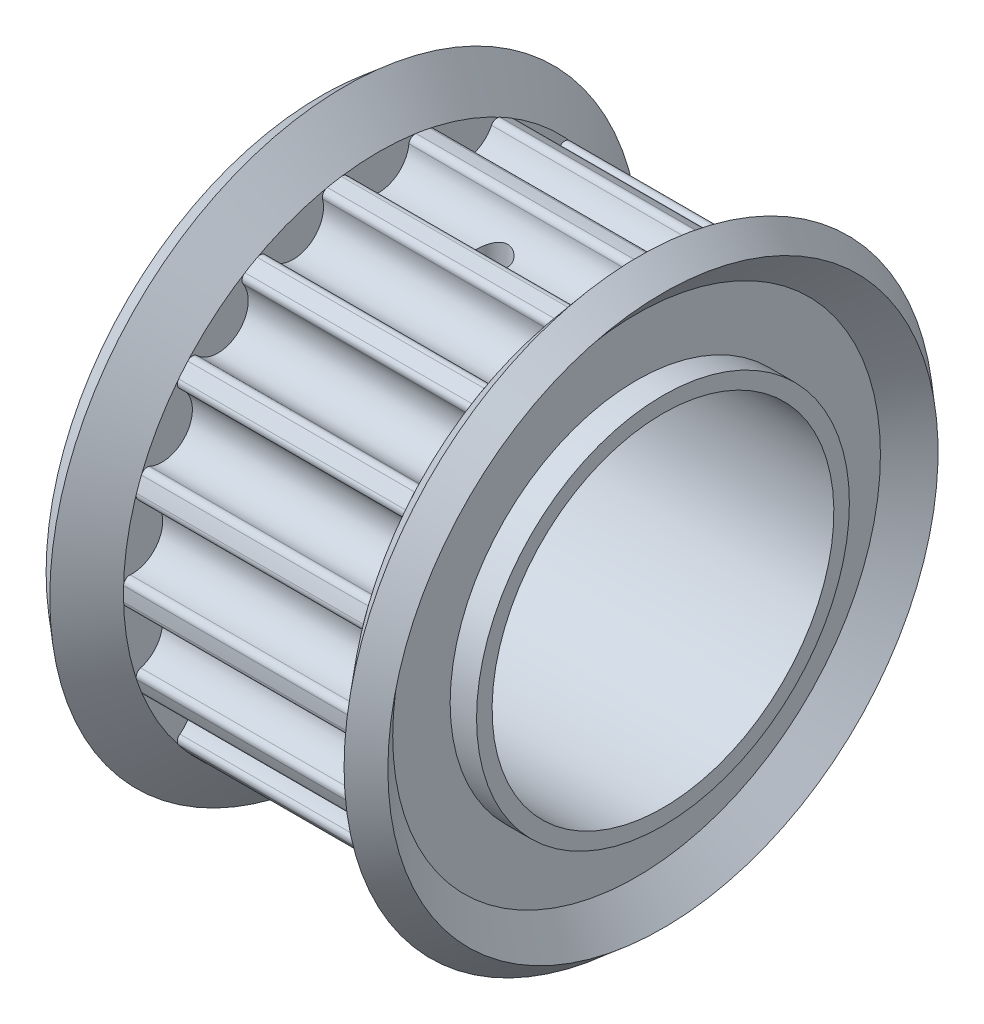
from build123d import *

# Parameters (mm, degrees)
CUT_EXTRUDE1_DEPTH = 6.5
CIRPATTERN1_COUNT  = 18
SKETCH4_W          = 11
SKETCH4_H          = 5.5
SKETCH5_R          = 0.5
CUT_EXTRUDE2_DEPTH = 10.5


with BuildPart() as part:
    # Sketch1 → Revolve1 (revolve)
    with BuildSketch(Plane.XY):
        Polygon((-5.5, 4), (5.5, 4), (5.5, 6), (3.65, 6), (3.65, 8.215), (-3.65, 8.215), (-3.65, 6), (-5.5, 6), align=None)
    revolve(axis=Axis((-16.041522885, 0, 0), (1, 0, 0)))

    # Sketch2 → Cut-Extrude1 (cut, symmetric)
    with BuildSketch(Plane(origin=(0, 0, 0), x_dir=(0, 0, -1), z_dir=(1, 0, 0))):
        with BuildLine():
            ThreePointArc((1.2, 8.126882859), (0, 8.215), (-1.2, 8.126882859))
            ThreePointArc((-1.2, 8.126882859), (-1.048214336, 8.087067355), (-0.971883761, 7.949962265))
            ThreePointArc((-0.971883761, 7.949962265), (0, 7.075), (0.971883761, 7.949962265))
            ThreePointArc((0.971883761, 7.949962265), (1.048214336, 8.087067355), (1.2, 8.126882859))
        make_face()
    cut_extrude1 = extrude(amount=CUT_EXTRUDE1_DEPTH, both=True, mode=Mode.SUBTRACT)

    # CirPattern1: Cut-Extrude1 ×18 about axis
    cirpattern1_axis = Axis((0, 0, 0), (1, 0, 0))
    for i in range(1, CIRPATTERN1_COUNT):
        add(cut_extrude1.rotate(cirpattern1_axis, i * 360 / CIRPATTERN1_COUNT), mode=Mode.SUBTRACT)

    # Sketch4 → Cut-Revolve1 (revolve, cut)
    with BuildSketch(Plane.XY):
        with Locations((0, 2.75)):
            Rectangle(SKETCH4_W, SKETCH4_H)
    revolve(axis=Axis((0, 0, 0), (-1, 0, 0)), mode=Mode.SUBTRACT)

    # Sketch5 → Cut-Extrude2 (cut, through all)
    with BuildSketch(Plane(origin=(0, 0, 0), x_dir=(1, 0, 0), z_dir=(0, 1, 0))):
        Circle(SKETCH5_R)
    extrude(amount=CUT_EXTRUDE2_DEPTH, mode=Mode.SUBTRACT)


with BuildPart() as body_2:
    # Sketch3 → Revolve2 (revolve)
    with BuildSketch(Plane.XY):
        Polygon((3.65, 6), (4.65, 6), (4.65, 7.848944657), (5.5, 8.854397763), (4.736326148, 9.5), (3.65, 8.215), align=None)
        Polygon((-3.65, 6), (-3.65, 8.215), (-4.736326148, 9.5), (-5.5, 8.854397763), (-4.65, 7.848944657), (-4.65, 6), align=None)
    revolve(axis=Axis((0, 0, 0), (1, 0, 0)))


solid = Compound([part.part, body_2.part])
